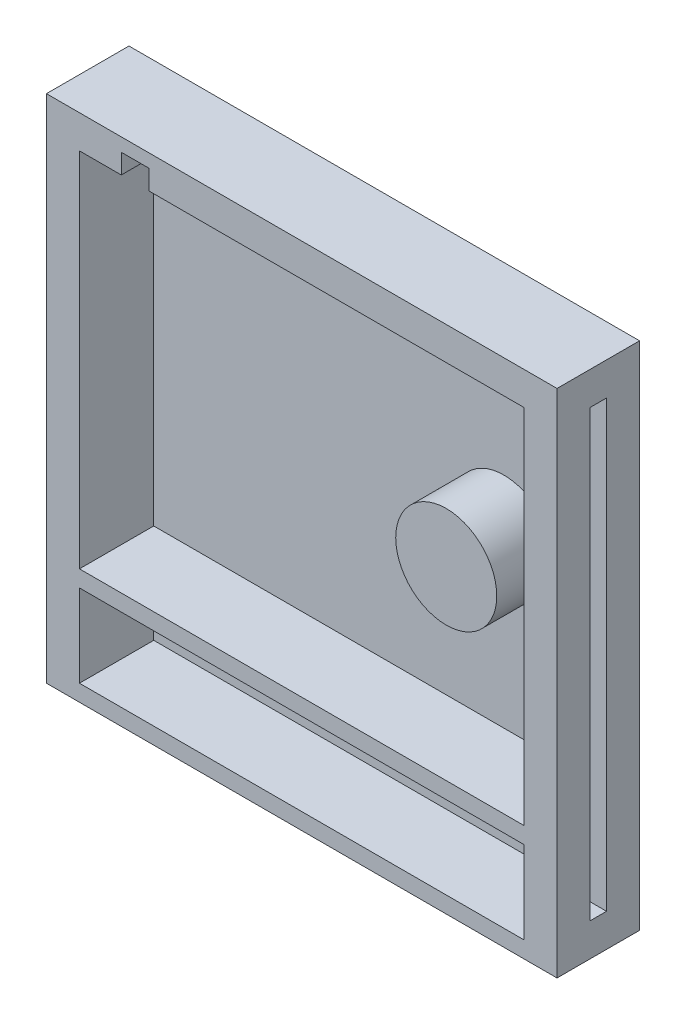
from build123d import *

# Parameters (mm, degrees)
SKETCH1_W           = 157.13579329
SKETCH1_H           = 157.13579329
BOSS_EXTRUDE1_DEPTH = 25.4
SKETCH2_W           = 136.81579329
SKETCH2_H           = 111.41579329
CUT_EXTRUDE1_DEPTH  = 22.86
SKETCH3_W           = 136.81579329
SKETCH3_H           = 25.4
CUT_EXTRUDE2_DEPTH  = 22.86
SKETCH5_W           = 5.08
SKETCH5_H           = 136.81579329
CUT_EXTRUDE3_DEPTH  = 7.62
SKETCH6_W           = 8.486375486
SKETCH6_H           = 6.062880986
CUT_EXTRUDE4_DEPTH  = 15.24
SKETCH8_R           = 15.547206761
BOSS_EXTRUDE3_DEPTH = 17.78


with BuildPart() as part:
    # Sketch1 → Boss-Extrude1 (new body)
    with BuildSketch(Plane.XY):
        Rectangle(SKETCH1_W, SKETCH1_H)
    extrude(amount=BOSS_EXTRUDE1_DEPTH)

    # Sketch2 → Cut-Extrude1 (cut)
    with BuildSketch(Plane.XY.offset(25.4)):
        with Locations((0, 12.7)):
            Rectangle(SKETCH2_W, SKETCH2_H)
    extrude(amount=-CUT_EXTRUDE1_DEPTH, mode=Mode.SUBTRACT)

    # Sketch3 → Cut-Extrude2 (cut)
    with BuildSketch(Plane.XY.offset(25.4)):
        with Locations((0, -60.787896645)):
            Rectangle(SKETCH3_W, SKETCH3_H)
    extrude(amount=-CUT_EXTRUDE2_DEPTH, mode=Mode.SUBTRACT)

    # Sketch5 → Cut-Extrude3 (cut)
    with BuildSketch(Plane.ZY.offset(78.567896645)):
        with Locations((12.7, 0)):
            Rectangle(SKETCH5_W, SKETCH5_H)
    cut_extrude3 = extrude(amount=-CUT_EXTRUDE3_DEPTH, mode=Mode.SUBTRACT)

    # Mirror1: Cut-Extrude3 across plane
    add(cut_extrude3.mirror(Plane(origin=(0, 0, 0), x_dir=(0, 0, 1), z_dir=(1, 0, 0))), mode=Mode.SUBTRACT)

    # Sketch6 → Cut-Extrude4 (cut)
    with BuildSketch(Plane.XY.offset(25.4)):
        with Locations((-51.293944562, 71.439337138)):
            Rectangle(SKETCH6_W, SKETCH6_H)
    extrude(amount=-CUT_EXTRUDE4_DEPTH, mode=Mode.SUBTRACT)

    # Sketch8 → Boss-Extrude3 (add)
    with BuildSketch(Plane.XY.offset(2.54)):
        with Locations((39.391283746, 8.898945532)):
            Circle(SKETCH8_R)
    extrude(amount=BOSS_EXTRUDE3_DEPTH)


solid = part.part
